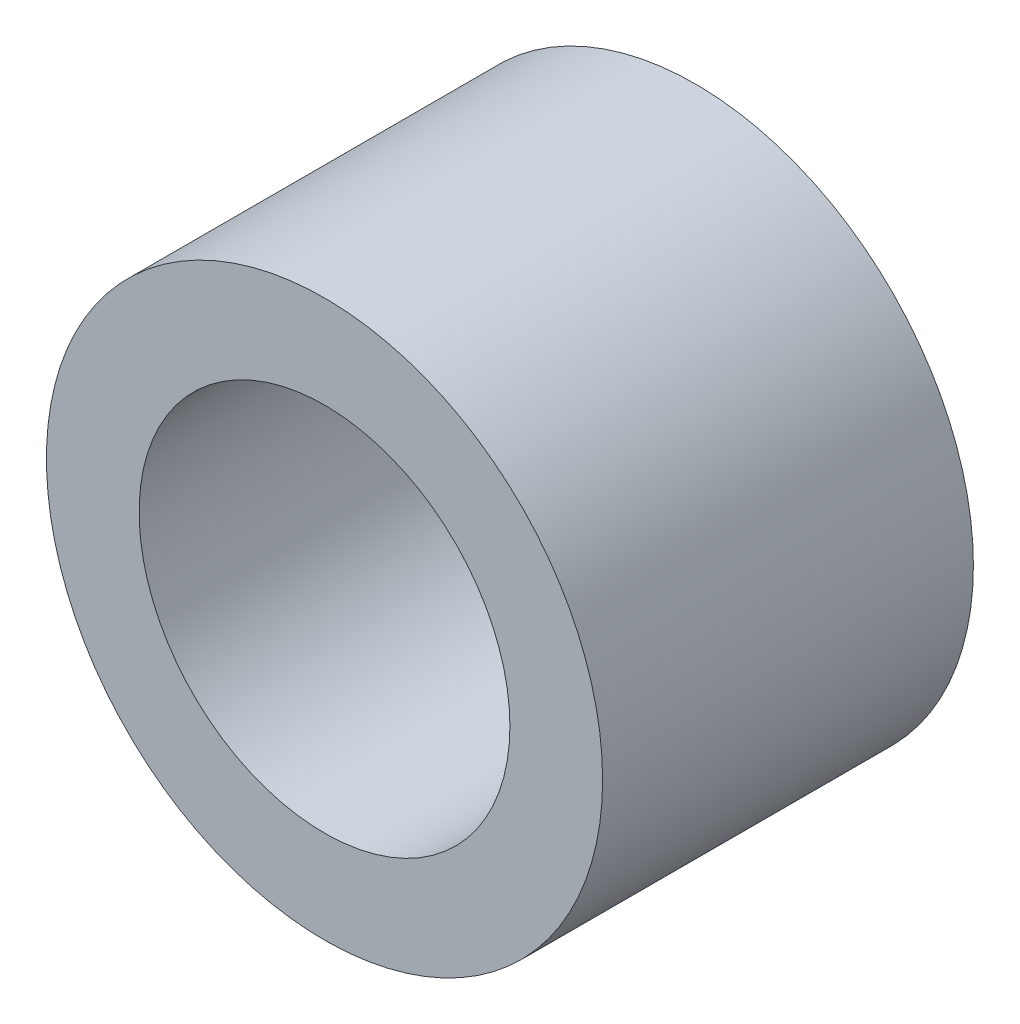
from build123d import *

# Parameters (mm, degrees)
SKETCH1_R      = 4.7625
SKETCH1_R_2    = 3.175
EXTRUDE1_DEPTH = 3.175


with BuildPart() as part:
    # Sketch1 → Extrude1 (new body, symmetric)
    with BuildSketch(Plane.XY):
        Circle(SKETCH1_R)
        Circle(SKETCH1_R_2, mode=Mode.SUBTRACT)
    extrude(amount=EXTRUDE1_DEPTH, both=True)


solid = part.part
